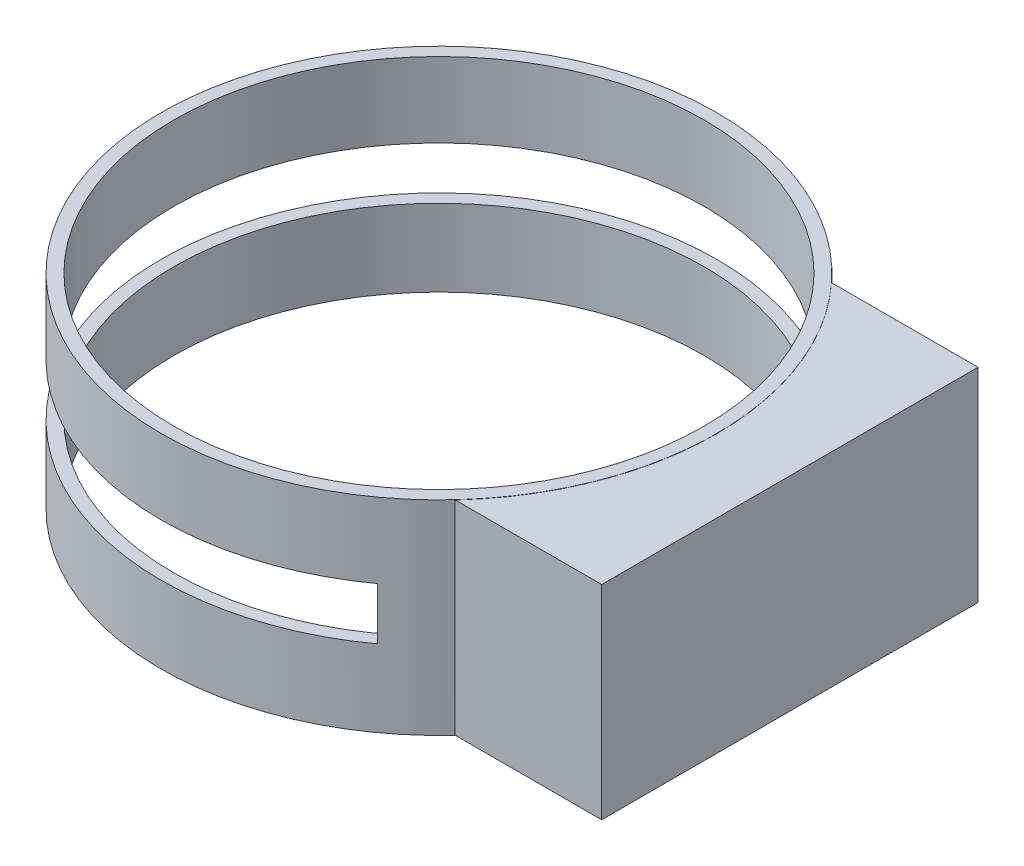
from build123d import *

# Parameters (mm, degrees)
CROQUIS1_R              = 68.105038976
CROQUIS1_R_2            = 65
SALIENTE_EXTRUIR1_DEPTH = 50
CROQUIS2_W              = 92.239777398
CROQUIS2_H              = 49.94465134
SALIENTE_EXTRUIR2_DEPTH = 86
CROQUIS3_R              = 65
CORTAR_EXTRUIR1_DEPTH   = 86
CROQUIS4_W              = 159.378049442
CROQUIS4_H              = 12.797364704
CORTAR_EXTRUIR2_DEPTH   = 144


with BuildPart() as part:
    # Croquis1 → Saliente-Extruir1 (new body)
    with BuildSketch(Plane(origin=(0, 0, 0), x_dir=(1, 0, 0), z_dir=(0, 1, 0))):
        Circle(CROQUIS1_R)
        Circle(CROQUIS1_R_2, mode=Mode.SUBTRACT)
    extrude(amount=SALIENTE_EXTRUIR1_DEPTH)

    # Croquis2 → Saliente-Extruir2 (add)
    with BuildSketch(Plane(origin=(0, 0, 0), x_dir=(0, 0, -1), z_dir=(1, 0, 0))):
        with Locations((0, 24.97232567)):
            Rectangle(CROQUIS2_W, CROQUIS2_H)
    extrude(amount=SALIENTE_EXTRUIR2_DEPTH)

    # Croquis3 → Cortar-Extruir1 (cut)
    with BuildSketch(Plane(origin=(0, 50, 0), x_dir=(1, 0, 0), z_dir=(0, 1, 0))):
        Circle(CROQUIS3_R)
    extrude(amount=-CORTAR_EXTRUIR1_DEPTH, mode=Mode.SUBTRACT)

    # Croquis4 → Cortar-Extruir2 (cut)
    with BuildSketch(Plane(origin=(40, 0, 0), x_dir=(0, 0, -1), z_dir=(1, 0, 0))):
        with Locations((-2.615595337, 25.25092872)):
            Rectangle(CROQUIS4_W, CROQUIS4_H)
    extrude(amount=-CORTAR_EXTRUIR2_DEPTH, mode=Mode.SUBTRACT)


solid = part.part
